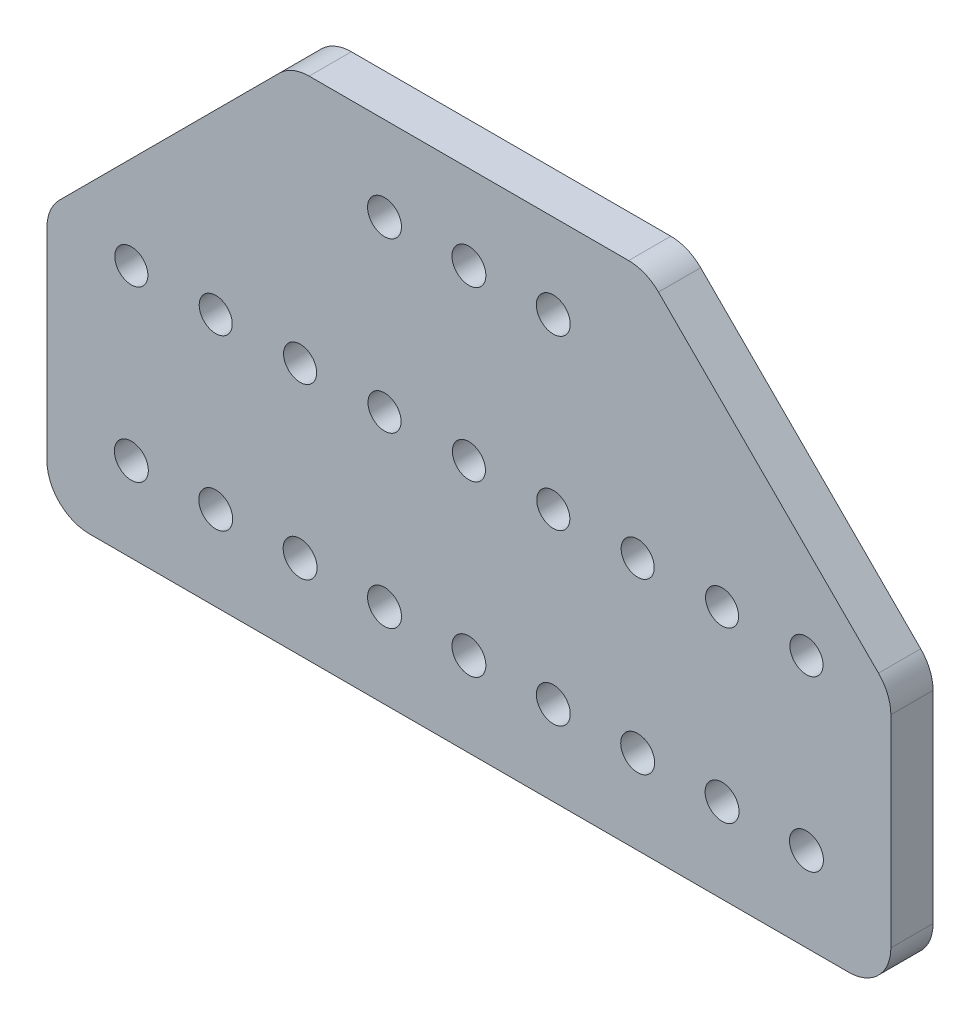
from build123d import *

# Parameters (mm, degrees)
SKETCH1_W               = 127
SKETCH1_H               = 82.55
BOSS_EXTRUDE1_DEPTH     = 6.35
SKETCH2_R               = 2.5527
CUT_EXTRUDE1_DEPTH      = 1
CUT_EXTRUDE1_DEPTH_BACK = 7.35
SKETCH3_R               = 2.4892
SKETCH3_R_2             = 2.5527
CUT_EXTRUDE2_DEPTH      = 7.35
CUT_EXTRUDE3_DEPTH      = 7.35
CUT_EXTRUDE4_DEPTH      = 7.35
FILLET1_R               = 6.35


with BuildPart() as part:
    # Sketch1 → Boss-Extrude1 (new body)
    with BuildSketch(Plane.XY):
        with Locations((63.5, 41.275)):
            Rectangle(SKETCH1_W, SKETCH1_H)
    extrude(amount=BOSS_EXTRUDE1_DEPTH)

    # Sketch2 → Cut-Extrude1 (cut, two sides)
    with BuildSketch(Plane(origin=(0, 0, 0), x_dir=(-1, 0, 0), z_dir=(0, 0, -1))) as cut_extrude1_sk:
        with Locations((-76.2, 63.5)):
            Circle(SKETCH2_R)
        with Locations((-63.5, 63.5)):
            Circle(SKETCH2_R)
        with Locations((-50.8, 63.5)):
            Circle(SKETCH2_R)
    extrude(amount=CUT_EXTRUDE1_DEPTH, mode=Mode.SUBTRACT)
    extrude(cut_extrude1_sk.sketch, amount=-CUT_EXTRUDE1_DEPTH_BACK, mode=Mode.SUBTRACT)

    # Sketch3 → Cut-Extrude2 (cut, through all)
    with BuildSketch(Plane(origin=(0, 0, 0), x_dir=(-1, 0, 0), z_dir=(0, 0, -1))):
        with Locations((-114.3, 38.1)):
            Circle(SKETCH3_R)
        with Locations((-114.3, 12.7)):
            Circle(SKETCH3_R_2)
        with Locations((-101.6, 38.1)):
            Circle(SKETCH3_R)
        with Locations((-101.6, 12.7)):
            Circle(SKETCH3_R_2)
        with Locations((-88.9, 38.1)):
            Circle(SKETCH3_R)
        with Locations((-88.9, 12.7)):
            Circle(SKETCH3_R_2)
        with Locations((-76.2, 38.1)):
            Circle(SKETCH3_R)
        with Locations((-76.2, 12.7)):
            Circle(SKETCH3_R_2)
        with Locations((-63.5, 38.1)):
            Circle(SKETCH3_R)
        with Locations((-63.5, 12.7)):
            Circle(SKETCH3_R_2)
        with Locations((-50.8, 38.1)):
            Circle(SKETCH3_R)
        with Locations((-50.8, 12.7)):
            Circle(SKETCH3_R_2)
        with Locations((-38.1, 38.1)):
            Circle(SKETCH3_R)
        with Locations((-38.1, 12.7)):
            Circle(SKETCH3_R_2)
        with Locations((-25.4, 38.1)):
            Circle(SKETCH3_R)
        with Locations((-25.4, 12.7)):
            Circle(SKETCH3_R_2)
        with Locations((-12.7, 38.1)):
            Circle(SKETCH3_R)
        with Locations((-12.7, 12.7)):
            Circle(SKETCH3_R_2)
    extrude(amount=-CUT_EXTRUDE2_DEPTH, mode=Mode.SUBTRACT)

    # Sketch4 → Cut-Extrude3 (cut, through all)
    with BuildSketch(Plane(origin=(0, 0, 0), x_dir=(-1, 0, 0), z_dir=(0, 0, -1))):
        Polygon((-83.82, 82.55), (-127, 39.37), (-127, 82.55), align=None)
        Polygon((-43.18, 82.55), (0, 82.55), (0, 39.37), align=None)
    extrude(amount=-CUT_EXTRUDE3_DEPTH, mode=Mode.SUBTRACT)

    # Sketch5 → Cut-Extrude4 (cut, through all)
    with BuildSketch(Plane(origin=(0, 0, 0), x_dir=(-1, 0, 0), z_dir=(0, 0, -1))):
        Polygon((-90.17, 76.2), (-36.83, 76.2), (-43.18, 82.55), (-83.82, 82.55), align=None)
    extrude(amount=-CUT_EXTRUDE4_DEPTH, mode=Mode.SUBTRACT)

    # Fillet1
    fillet1_edges = [part.edges().sort_by_distance(p)[0] for p in [
        (127, 39.37, 3.175),
        (0, 39.37, 3.175),
        (90.17, 76.2, 3.175),
        (36.83, 76.2, 3.175),
        (127, 0, 3.175),
        (0, 0, 3.175),
    ]]
    fillet(fillet1_edges, radius=FILLET1_R)


solid = part.part
